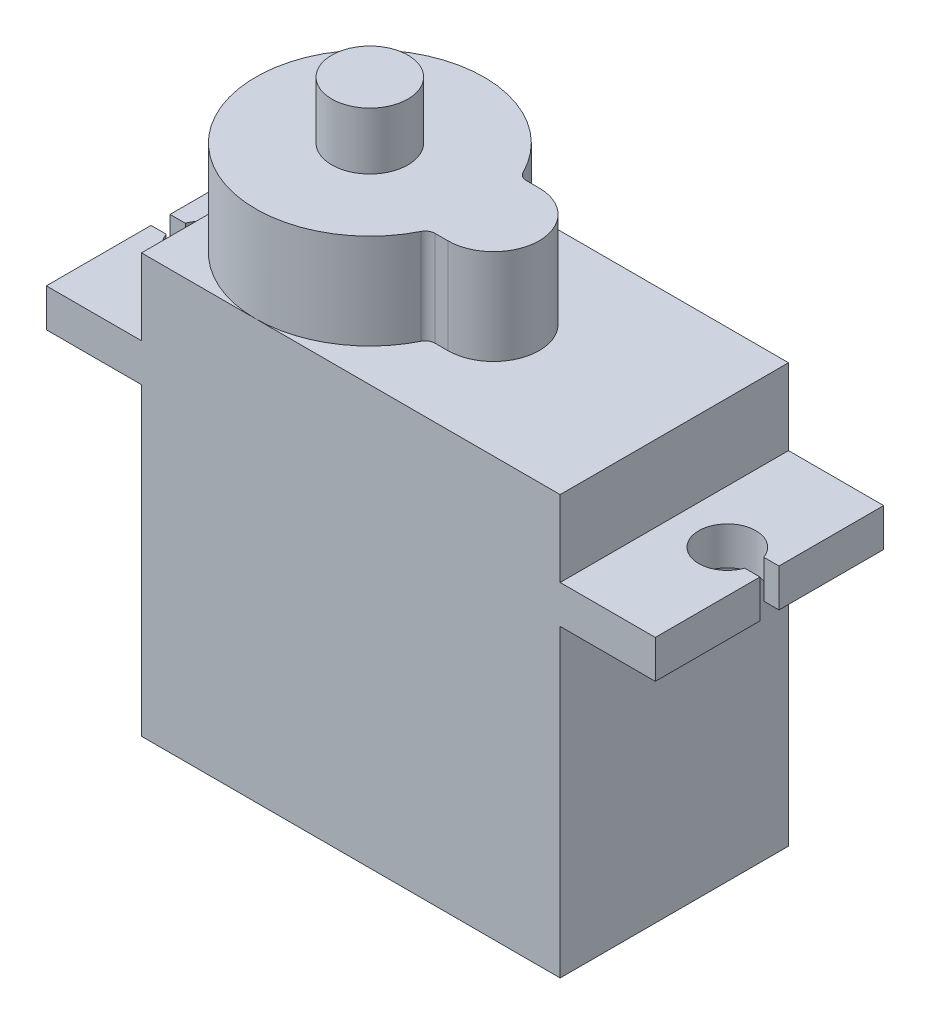
from build123d import *

# Parameters (mm, degrees)
BOSS_EXTRUDE1_DEPTH = 12
BOSS_EXTRUDE2_DEPTH = 5
CUT_EXTRUDE1_START  = -19
CUT_EXTRUDE1_DEPTH  = 29
SKETCH4_R           = 2
BOSS_EXTRUDE3_DEPTH = 3
FILLET1_R           = 0.5


with BuildPart() as part:
    # Sketch1 → Boss-Extrude1 (new body)
    with BuildSketch(Plane.XY):
        Polygon((11, 7), (16, 7), (16, 5), (11, 5), (11, -11), (-11, -11), (-11, 5), (-16, 5), (-16, 7), (-11, 7), (-11, 11), (11, 11), align=None)
    extrude(amount=-BOSS_EXTRUDE1_DEPTH)

    # Sketch2 → Boss-Extrude2 (add)
    with BuildSketch(Plane(origin=(0, 11, 0), x_dir=(1, 0, 0), z_dir=(0, 1, 0))):
        with BuildLine():
            Line((1.499090834, 8.4), (0.499090834, 8.4))
            ThreePointArc((0.499090834, 8.4), (-11, 6), (0.499090834, 3.6))
            Line((0.499090834, 3.6), (1.499090834, 3.6))
            ThreePointArc((1.499090834, 3.6), (3.899090834, 6), (1.499090834, 8.4))
        make_face()
    extrude(amount=BOSS_EXTRUDE2_DEPTH)

    # Sketch3 → Cut-Extrude1 (cut)
    with BuildSketch(Plane(origin=(0, 7, 0), x_dir=(1, 0, 0), z_dir=(0, 1, 0)).offset(CUT_EXTRUDE1_START)):
        with BuildLine():
            Line((15.2, 6.5), (16, 6.5))
            Line((16, 6.5), (16, 5.5))
            Line((16, 5.5), (15.2, 5.5))
            ThreePointArc((15.2, 5.5), (12.285786438, 6), (15.2, 6.5))
        make_face()
    cut_extrude1 = extrude(amount=CUT_EXTRUDE1_DEPTH, mode=Mode.SUBTRACT)

    # Mirror1: Cut-Extrude1 across plane
    add(cut_extrude1.mirror(Plane(origin=(0, 0, 0), x_dir=(0, 0, 1), z_dir=(1, 0, 0))), mode=Mode.SUBTRACT)

    # Sketch4 → Boss-Extrude3 (add)
    with BuildSketch(Plane(origin=(0, 16, 0), x_dir=(1, 0, 0), z_dir=(0, 1, 0))):
        with Locations((-5, 6)):
            Circle(SKETCH4_R)
    extrude(amount=BOSS_EXTRUDE3_DEPTH)

    # Fillet1
    fillet1_edges = [part.edges().sort_by_distance(p)[0] for p in [
        (0.499090834, 13.5, -8.4),
        (0.499090834, 13.5, -3.6),
    ]]
    fillet(fillet1_edges, radius=FILLET1_R)


solid = part.part
